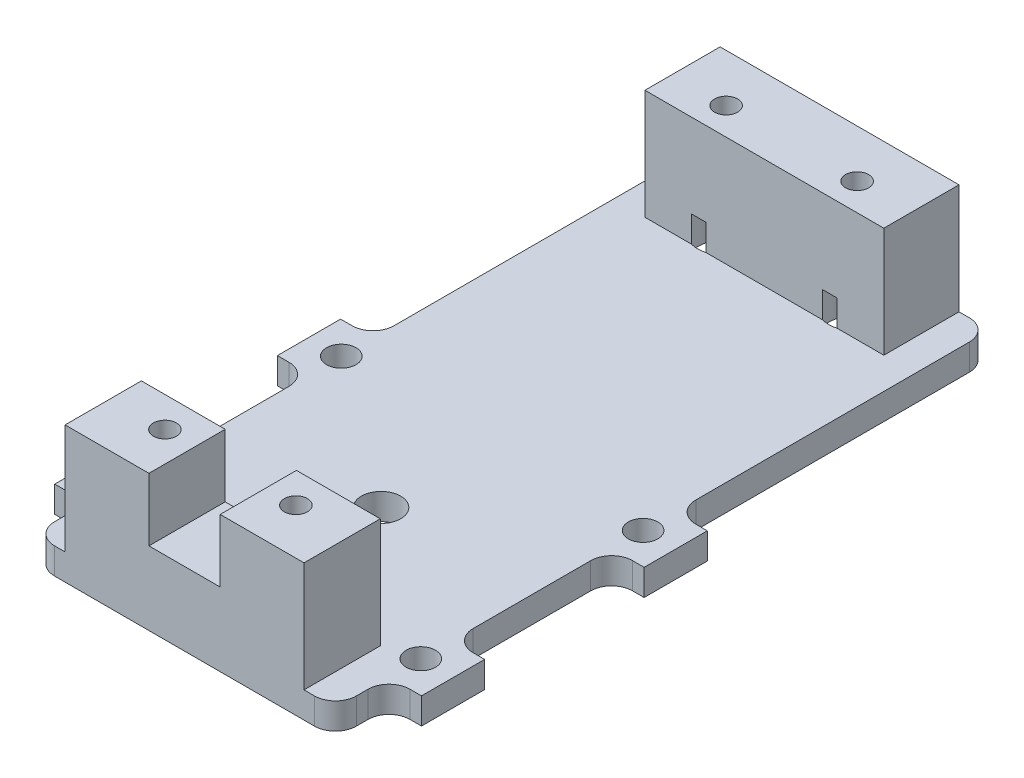
from build123d import *

# Parameters (mm, degrees)
SKETCH1_R                           = 2.38125
BOSS_EXTRUDE1_DEPTH                 = 3.175
F_9_64_0_14063_DIAMETER_HOLE1_D     = 3.572002
F_9_64_0_14063_DIAMETER_HOLE1_DEPTH = 3.175
FILLET1_R                           = 2.54
SKETCH9_W                           = 28.956
SKETCH9_H                           = 9.242923456
SKETCH9_R                           = 1.397
SKETCH9_H_2                         = 9.1095327
BOSS_EXTRUDE3_DEPTH                 = 16.51
SKETCH10_R                          = 3.429
CUT_EXTRUDE1_DEPTH                  = 6.35
SKETCH11_W                          = 8.636
SKETCH11_H                          = 9.242923456
CUT_EXTRUDE2_DEPTH                  = 7.62


with BuildPart() as part:
    # Sketch1 → Boss-Extrude1 (new body)
    with BuildSketch(Plane(origin=(0, 0, 0), x_dir=(1, 0, 0), z_dir=(0, 1, 0))):
        Polygon((18.288, -9.6647), (22.225, -9.6647), (22.225, -17.3228), (18.288, -17.3228), (18.288, -23.8125), (-18.288, -23.8125), (-18.288, -17.3228), (-22.225, -17.3228), (-22.225, -9.6647), (-18.288, -9.6647), (-18.288, 9.6647), (-22.225, 9.6647), (-22.225, 17.3228), (-18.288, 17.3228), (-18.288, 55.5625), (18.288, 55.5625), (18.288, 17.3228), (22.225, 17.3228), (22.225, 9.6647), (18.288, 9.6647), align=None)
        with Locations((0, 0.004315819)):
            Circle(SKETCH1_R, mode=Mode.SUBTRACT)
    extrude(amount=BOSS_EXTRUDE1_DEPTH)

    # 9/64 (0.14063) Diameter Hole1
    with Locations(Plane.XZ):
        with Locations((18.287999999, -13.474700001), (18.288, 13.466068362), (-18.288, -13.470384182), (-18.288, 13.470384182)):
            Hole(F_9_64_0_14063_DIAMETER_HOLE1_D / 2, depth=F_9_64_0_14063_DIAMETER_HOLE1_DEPTH)

    # Fillet1
    fillet1_edges = [part.edges().sort_by_distance(p)[0] for p in [
        (18.288, 1.5875, 23.8125),
        (-18.288, 1.5875, 23.8125),
        (-18.288, 1.5875, 17.3228),
        (-18.288, 1.5875, 9.6647),
        (-18.288, 1.5875, -9.6647),
        (-18.288, 1.5875, -17.3228),
        (-18.288, 1.5875, -55.5625),
        (18.288, 1.5875, -55.5625),
        (18.288, 1.5875, -17.3228),
        (18.288, 1.5875, -9.6647),
        (18.288, 1.5875, 9.6647),
        (18.288, 1.5875, 17.3228),
    ]]
    fillet(fillet1_edges, radius=FILLET1_R)

    # Sketch9 → Boss-Extrude3 (add)
    with BuildSketch(Plane(origin=(0, 0, 0), x_dir=(1, 0, 0), z_dir=(0, 1, 0))):
        with Locations((0, -19.191038272)):
            Rectangle(SKETCH9_W, SKETCH9_H)
        with Locations((-7.9375, -18.25625)):
            Circle(SKETCH9_R, mode=Mode.SUBTRACT)
        with Locations((7.9375, -18.25625)):
            Circle(SKETCH9_R, mode=Mode.SUBTRACT)
        with Locations((0.012736117, 51.00773365)):
            Rectangle(SKETCH9_W, SKETCH9_H_2)
        with Locations((-7.9375, 49.76495)):
            Circle(SKETCH9_R, mode=Mode.SUBTRACT)
        with Locations((7.9375, 49.76495)):
            Circle(SKETCH9_R, mode=Mode.SUBTRACT)
    extrude(amount=BOSS_EXTRUDE3_DEPTH)

    # Sketch10 → Cut-Extrude1 (cut)
    with BuildSketch(Plane.XZ):
        with Locations((7.9375, 18.25625)):
            Circle(SKETCH10_R)
        with Locations((-7.9375, 18.25625)):
            Circle(SKETCH10_R)
        with Locations((7.9375, -49.76495)):
            Circle(SKETCH10_R)
        with Locations((-7.9375, -49.76495)):
            Circle(SKETCH10_R)
    extrude(amount=-CUT_EXTRUDE1_DEPTH, mode=Mode.SUBTRACT)

    # Sketch11 → Cut-Extrude2 (cut)
    with BuildSketch(Plane(origin=(0, 16.51, 0), x_dir=(1, 0, 0), z_dir=(0, 1, 0))):
        with Locations((0, -19.191038272)):
            Rectangle(SKETCH11_W, SKETCH11_H)
    extrude(amount=-CUT_EXTRUDE2_DEPTH, mode=Mode.SUBTRACT)


solid = part.part
